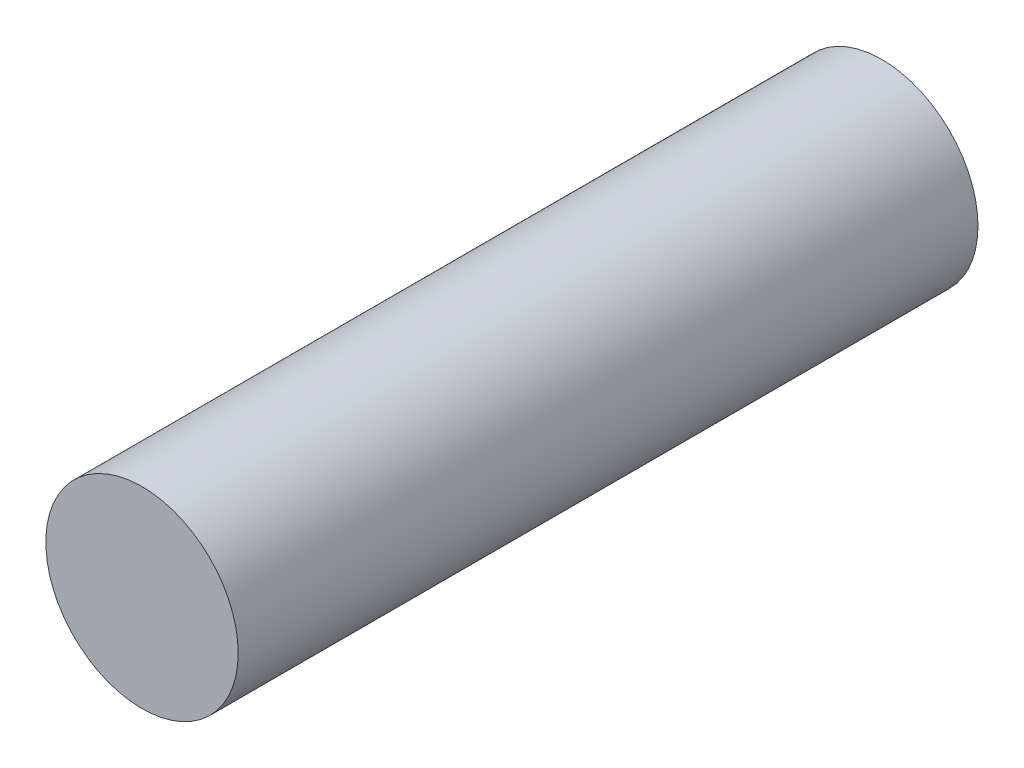
from build123d import *

# Parameters (mm, degrees)
IZIM1_R                     = 13
Y_KSEKLIK_EKSTR_ZYON1_DEPTH = 100


with BuildPart() as part:
    # Çizim1 → Yükseklik-Ekstrüzyon1 (new body)
    with BuildSketch(Plane.XY):
        Circle(IZIM1_R)
    extrude(amount=Y_KSEKLIK_EKSTR_ZYON1_DEPTH)


solid = part.part
